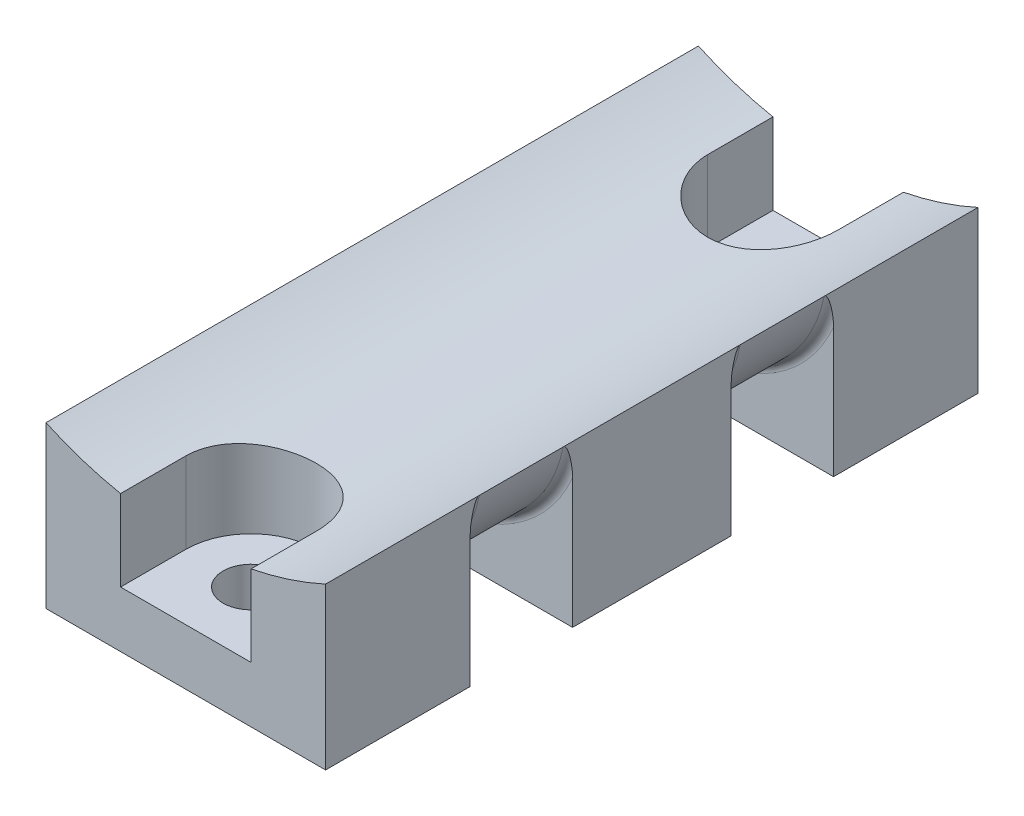
from build123d import *

# Parameters (mm, degrees)
BOSS_EXTRUDE1_DEPTH = 35
CUT_EXTRUDE1_DEPTH  = 30
CUT_EXTRUDE3_DEPTH  = 5.5
CUT_EXTRUDE4_DEPTH  = 5.5
SKETCH7_R           = 1.5
CUT_EXTRUDE5_DEPTH  = 4
FILLET1_R           = 0.5


with BuildPart() as part:
    # Sketch1 → Boss-Extrude1 (new body)
    with BuildSketch(Plane.XY):
        with BuildLine():
            Line((-7.5, 2.562310746), (7.5, 2.562310746))
            Line((7.5, 2.562310746), (7.5, 11.199242574))
            ThreePointArc((7.5, 11.199242574), (0, 9.562310746), (-7.5, 11.199242574))
            Line((-7.5, 11.199242574), (-7.5, 2.562310746))
        make_face()
    extrude(amount=BOSS_EXTRUDE1_DEPTH)

    # Sketch3 → Cut-Extrude1 (cut)
    with BuildSketch(Plane(origin=(0, 5.562310746, 0), x_dir=(-1, 0, 0), z_dir=(0, -1, 0))):
        with BuildLine():
            Line((-3.5, -3.5), (-3.5, 2.919890279))
            Line((-3.5, 2.919890279), (3.5, 2.919890279))
            Line((3.5, 2.919890279), (3.5, -3.5))
            ThreePointArc((3.5, -3.5), (0, -7), (-3.5, -3.5))
        make_face()
        with BuildLine():
            Line((3.5, -31.5), (3.5, -38.189637839))
            Line((3.5, -38.189637839), (-3.5, -38.189637839))
            Line((-3.5, -38.189637839), (-3.5, -31.5))
            ThreePointArc((-3.5, -31.5), (0, -28), (3.5, -31.5))
        make_face()
    extrude(amount=-CUT_EXTRUDE1_DEPTH, mode=Mode.SUBTRACT)

    # Sketch5 → Cut-Extrude3 (cut)
    with BuildSketch(Plane.XY.offset(7.75)):
        with BuildLine():
            Line((-7.5, 11.199242574), (-7.5, 2.562310746))
            Line((-7.5, 2.562310746), (7.5, 2.562310746))
            Line((7.5, 2.562310746), (7.5, 11.199242574))
            ThreePointArc((7.5, 11.199242574), (0, 5.062310746), (-7.5, 11.199242574))
        make_face()
    extrude(amount=CUT_EXTRUDE3_DEPTH, mode=Mode.SUBTRACT)

    # Sketch6 → Cut-Extrude4 (cut)
    with BuildSketch(Plane.XY.offset(27.25)):
        with BuildLine():
            Line((-7.5, 11.199242574), (-7.5, 2.562310746))
            Line((-7.5, 2.562310746), (7.5, 2.562310746))
            Line((7.5, 2.562310746), (7.5, 11.199242574))
            ThreePointArc((7.5, 11.199242574), (0, 5.062310746), (-7.5, 11.199242574))
        make_face()
    extrude(amount=-CUT_EXTRUDE4_DEPTH, mode=Mode.SUBTRACT)

    # Sketch7 → Cut-Extrude5 (cut, through all)
    with BuildSketch(Plane(origin=(0, 5.562310746, 0), x_dir=(1, 0, 0), z_dir=(0, 1, 0))):
        with Locations((0, -3.5)):
            Circle(SKETCH7_R)
        with Locations((0, -31.5)):
            Circle(SKETCH7_R)
    extrude(amount=-CUT_EXTRUDE5_DEPTH, mode=Mode.SUBTRACT)

    # Fillet1
    fillet1_edges = [part.edges().sort_by_distance(p)[0] for p in [
        (0, 5.062310746, 7.75),
        (0, 5.062310746, 13.25),
        (0, 5.062310746, 21.75),
        (0, 5.062310746, 27.25),
    ]]
    fillet(fillet1_edges, radius=FILLET1_R)


solid = part.part
